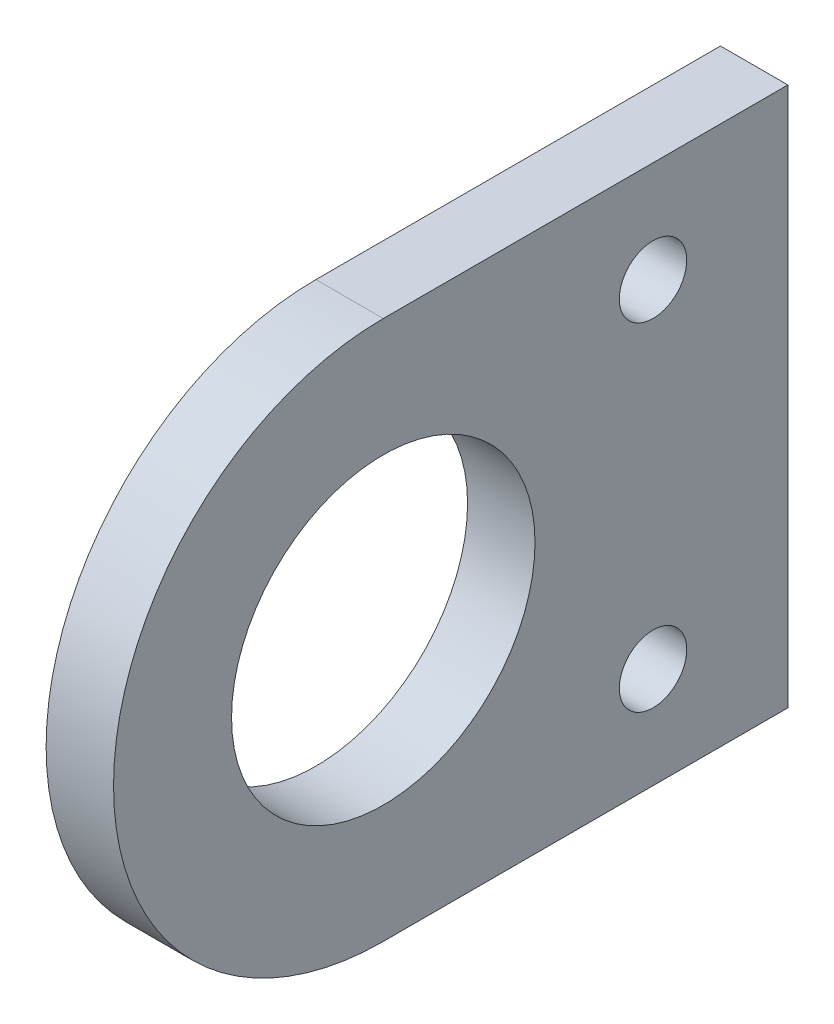
from build123d import *

# Parameters (mm, degrees)
SKETCH1_R           = 14.2875
SKETCH1_R_2         = 3.175
BOSS_EXTRUDE1_DEPTH = 6.35


with BuildPart() as part:
    # Sketch1 → Boss-Extrude1 (new body)
    with BuildSketch(Plane(origin=(0, 0, 0), x_dir=(0, 0, -1), z_dir=(1, 0, 0))):
        with BuildLine():
            Line((0, 25.4), (38.1, 25.4))
            Line((38.1, 25.4), (38.1, -25.4))
            Line((38.1, -25.4), (0, -25.4))
            ThreePointArc((0, -25.4), (-25.4, 0), (0, 25.4))
        make_face()
        Circle(SKETCH1_R, mode=Mode.SUBTRACT)
        with Locations((25.4, 15.875)):
            Circle(SKETCH1_R_2, mode=Mode.SUBTRACT)
        with Locations((25.4, -15.875)):
            Circle(SKETCH1_R_2, mode=Mode.SUBTRACT)
    extrude(amount=BOSS_EXTRUDE1_DEPTH)


solid = part.part
